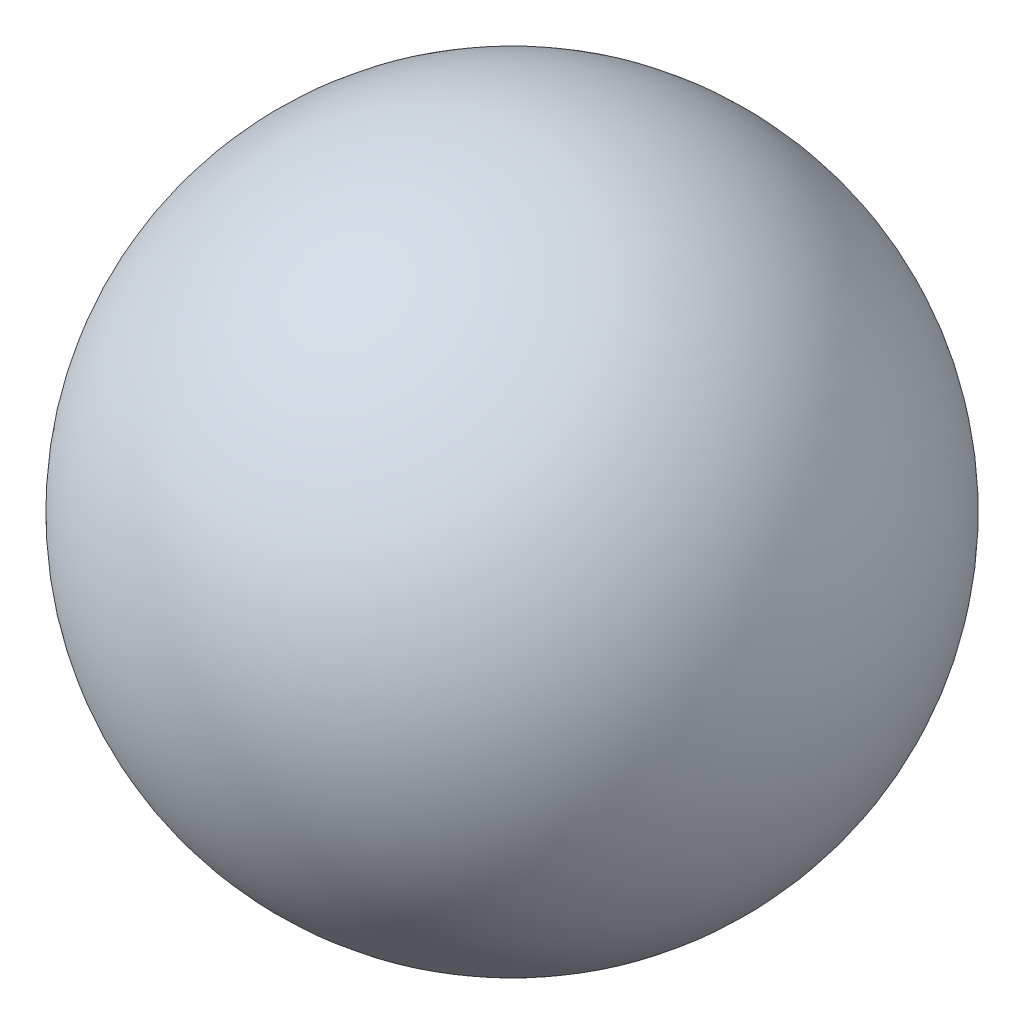
from build123d import *


with BuildPart() as part:
    # Schizzo1 → Rivoluzione1 (revolve)
    with BuildSketch(Plane(origin=(0, 0, 0), x_dir=(0, 0, -1), z_dir=(1, 0, 0))):
        with BuildLine():
            Line((0, -18), (0, 18))
            ThreePointArc((0, 18), (18, 0), (0, -18))
        make_face()
    revolve(axis=Axis((0, -18, 0), (0, 1, 0)))


solid = part.part
